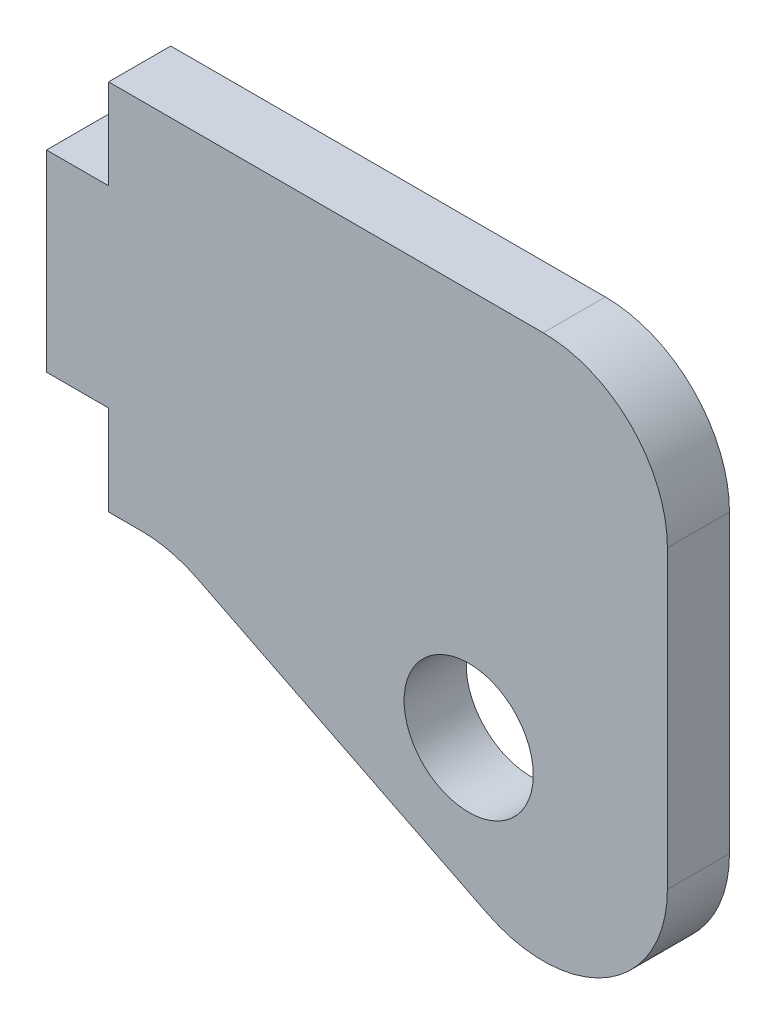
from build123d import *

# Parameters (mm, degrees)
BOSS_EXTRUDE1_DEPTH = 3.175
FILLET1_R           = 6.35
SKETCH3_R           = 3.302
CUT_EXTRUDE1_DEPTH  = 3.175
SKETCH4_W           = 3.175
SKETCH4_H           = 4.60375
CUT_EXTRUDE2_DEPTH  = 3.175


with BuildPart() as part:
    # Sketch1 → Boss-Extrude1 (new body)
    with BuildSketch(Plane.XY):
        Polygon((0, -9.525), (6.35, -9.525), (31.75, -22.225), (31.75, 9.525), (0, 9.525), align=None)
    extrude(amount=BOSS_EXTRUDE1_DEPTH)

    # Fillet1
    fillet1_edges = [part.edges().sort_by_distance(p)[0] for p in [
        (31.75, 9.525, 1.5875),
        (31.75, -22.225, 1.5875),
        (6.35, -9.525, 1.5875),
    ]]
    fillet(fillet1_edges, radius=FILLET1_R)

    # Sketch3 → Cut-Extrude1 (cut)
    with BuildSketch(Plane.XY.offset(3.175)):
        with Locations((21.588299978, -10.315871599)):
            Circle(SKETCH3_R)
    extrude(amount=-CUT_EXTRUDE1_DEPTH, mode=Mode.SUBTRACT)

    # Sketch4 → Cut-Extrude2 (cut)
    with BuildSketch(Plane.XY.offset(3.175)):
        with Locations((1.5875, 7.223125)):
            Rectangle(SKETCH4_W, SKETCH4_H)
        with Locations((1.5875, -7.223125)):
            Rectangle(SKETCH4_W, SKETCH4_H)
    extrude(amount=-CUT_EXTRUDE2_DEPTH, mode=Mode.SUBTRACT)


solid = part.part
